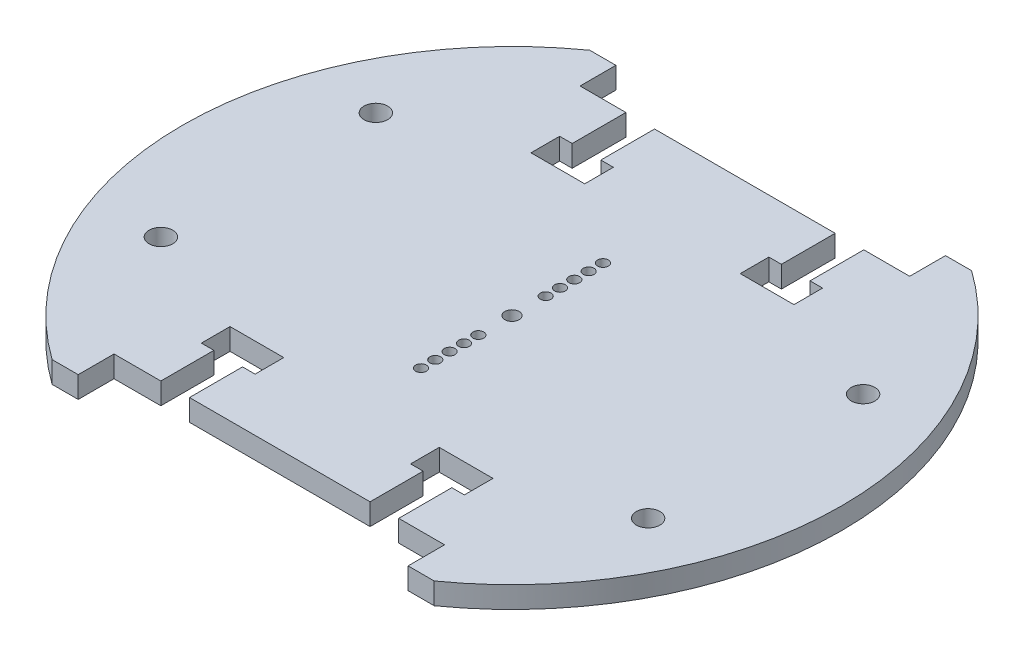
from build123d import *

# Parameters (mm, degrees)
SKETCH1_R           = 1.65
SKETCH1_R_2         = 1
SKETCH1_R_3         = 0.75
BOSS_EXTRUDE1_DEPTH = 3
SKETCH2_W           = 4
SKETCH2_H           = 7.5
SKETCH2_W_2         = 7.5
SKETCH2_H_2         = 4
SKETCH2_H_3         = 7.405429953
CUT_EXTRUDE1_DEPTH  = 4


with BuildPart() as part:
    # Sketch1 → Boss-Extrude1 (new body)
    with BuildSketch(Plane(origin=(0, 0, 0), x_dir=(1, 0, 0), z_dir=(0, 1, 0))):
        with BuildLine():
            Line((-26.64113361, 37.5), (-23, 37.5))
            Line((-23, 37.5), (-23, 32.5))
            Line((-23, 32.5), (23, 32.5))
            Line((23, 32.5), (23, 37.5))
            Line((23, 37.5), (26.64113361, 37.5))
            ThreePointArc((26.64113361, 37.5), (46, 0), (26.64113361, -37.5))
            Line((26.64113361, -37.5), (23, -37.5))
            Line((23, -37.5), (23, -32.405429953))
            Line((23, -32.405429953), (-23.13261865, -32.405429953))
            Line((-23.13261865, -32.405429953), (-23.13261865, -37.405429953))
            Line((-23.13261865, -37.405429953), (-26.77375226, -37.405429953))
            ThreePointArc((-26.77375226, -37.405429953), (-45.999927904, 0.081442004), (-26.64113361, 37.5))
        make_face()
        with Locations((34, -15)):
            Circle(SKETCH1_R, mode=Mode.SUBTRACT)
        with Locations((34, 15)):
            Circle(SKETCH1_R, mode=Mode.SUBTRACT)
        with Locations((-34, 15)):
            Circle(SKETCH1_R, mode=Mode.SUBTRACT)
        with Locations((-34, -15)):
            Circle(SKETCH1_R, mode=Mode.SUBTRACT)
        Circle(SKETCH1_R_2, mode=Mode.SUBTRACT)
        with Locations((0, 8.7)):
            Circle(SKETCH1_R_3, mode=Mode.SUBTRACT)
        with Locations((0, 10.7)):
            Circle(SKETCH1_R_3, mode=Mode.SUBTRACT)
        with Locations((0, 12.7)):
            Circle(SKETCH1_R_3, mode=Mode.SUBTRACT)
        with Locations((0, 6.7)):
            Circle(SKETCH1_R_3, mode=Mode.SUBTRACT)
        with Locations((0, 4.7)):
            Circle(SKETCH1_R_3, mode=Mode.SUBTRACT)
        with Locations((0, -12.7)):
            Circle(SKETCH1_R_3, mode=Mode.SUBTRACT)
        with Locations((0, -10.7)):
            Circle(SKETCH1_R_3, mode=Mode.SUBTRACT)
        with Locations((0, -8.7)):
            Circle(SKETCH1_R_3, mode=Mode.SUBTRACT)
        with Locations((0, -6.7)):
            Circle(SKETCH1_R_3, mode=Mode.SUBTRACT)
        with Locations((0, -4.7)):
            Circle(SKETCH1_R_3, mode=Mode.SUBTRACT)
    extrude(amount=BOSS_EXTRUDE1_DEPTH)

    # Sketch2 → Cut-Extrude1 (cut, through all)
    with BuildSketch(Plane(origin=(0, 3, 0), x_dir=(1, 0, 0), z_dir=(0, 1, 0))):
        with Locations((-14.6, 28.75)):
            Rectangle(SKETCH2_W, SKETCH2_H)
        Polygon((-12.6, 25), (-16.6, 25), (-18.35, 25), (-18.35, 21), (-10.85, 21), (-10.85, 25), align=None)
        with Locations((14.6, 28.75)):
            Rectangle(SKETCH2_W, SKETCH2_H)
        with Locations((14.6, 23)):
            Rectangle(SKETCH2_W_2, SKETCH2_H_2)
        with Locations((-14.6, -23)):
            Rectangle(SKETCH2_W_2, SKETCH2_H_2)
        with Locations((-14.6, -28.702714977)):
            Rectangle(SKETCH2_W, SKETCH2_H_3)
        Polygon((12.6, -25), (16.6, -25), (18.35, -25), (18.35, -21), (10.85, -21), (10.85, -25), align=None)
        with Locations((14.6, -28.702714977)):
            Rectangle(SKETCH2_W, SKETCH2_H_3)
    extrude(amount=-CUT_EXTRUDE1_DEPTH, mode=Mode.SUBTRACT)


solid = part.part
